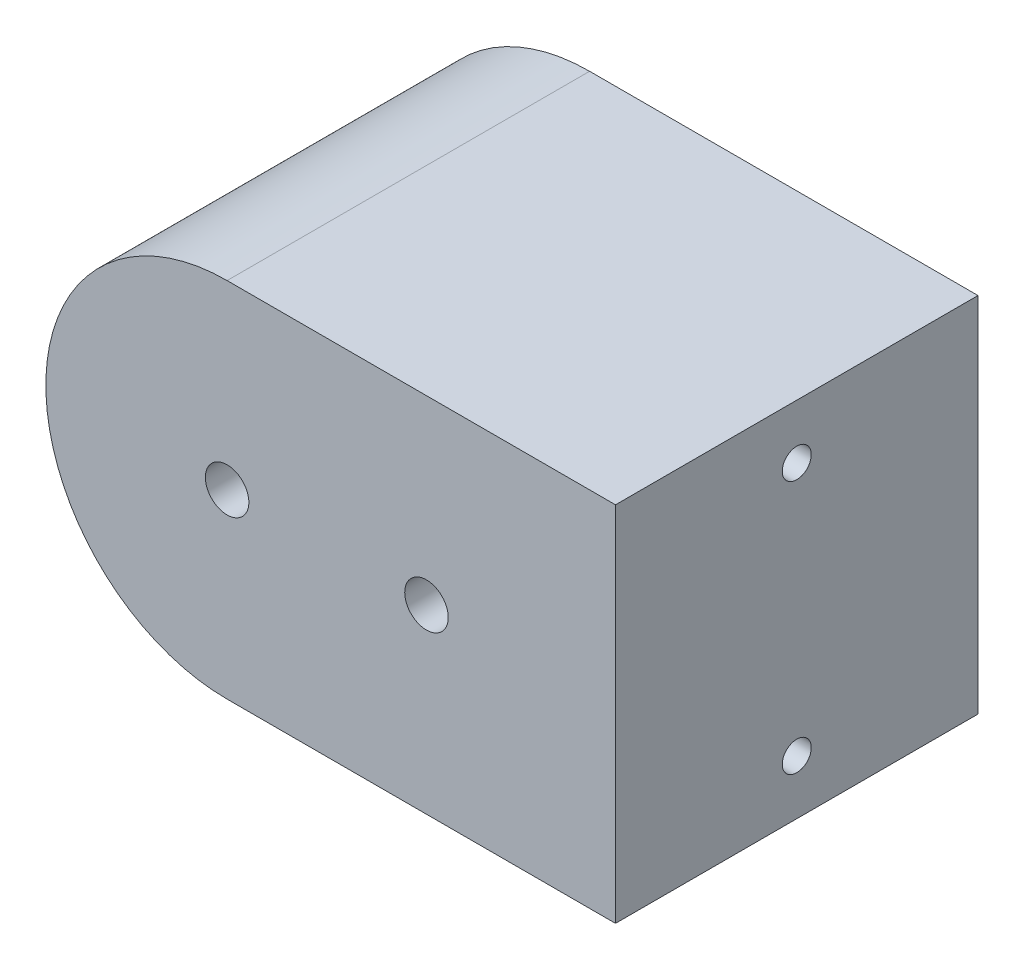
from build123d import *

# Parameters (mm, degrees)
BOSS_EXTRUDE1_DEPTH       = 70
SCALE1_SCALE              = 1.428571429
F_12_0MM_DOWEL_HOLE1_D    = 12
F_8_0MM_DOWEL_HOLE3_D     = 8
F_8_0MM_DOWEL_HOLE3_DEPTH = 20
F_8_0MM_DOWEL_HOLE3_TIP   = 2.403442476


with BuildPart() as part:
    # Sketch1 → Boss-Extrude1 (new body)
    with BuildSketch(Plane.XY):
        with BuildLine():
            Line((0, 0), (-75, 0))
            ThreePointArc((-75, 0), (-110, 35), (-75, 70))
            Line((-75, 70), (0, 70))
            Line((0, 70), (0, 0))
        make_face()
    extrude(amount=BOSS_EXTRUDE1_DEPTH)


with BuildPart() as part_1:
    # Scale1: scaled about (-51.542183312, 35, 35)
    add(part.part.scale(SCALE1_SCALE).moved(Location((22.089507134, -15, -15))))

    # Ø12.0mm Dowel Hole1 (through all)
    with Locations(Plane(origin=(-30.053350009, 35, -15), x_dir=(-1, 0, 0), z_dir=(0, 0, -1))):
        with Locations((0, 0), (55, 0)):
            Hole(F_12_0MM_DOWEL_HOLE1_D / 2)

    # Ø8.0mm Dowel Hole3
    with Locations(Plane(origin=(22.089507134, 0, 0), x_dir=(0, 0, -1), z_dir=(1, 0, 0))):
        with Locations((-35, 70), (-35, 0)):
            Hole(F_8_0MM_DOWEL_HOLE3_D / 2, depth=F_8_0MM_DOWEL_HOLE3_DEPTH)
            with Locations((0, 0, -(F_8_0MM_DOWEL_HOLE3_DEPTH + F_8_0MM_DOWEL_HOLE3_TIP / 2))):  # 118° drill point
                Cone(0, F_8_0MM_DOWEL_HOLE3_D / 2, F_8_0MM_DOWEL_HOLE3_TIP, mode=Mode.SUBTRACT)


solid = part_1.part
